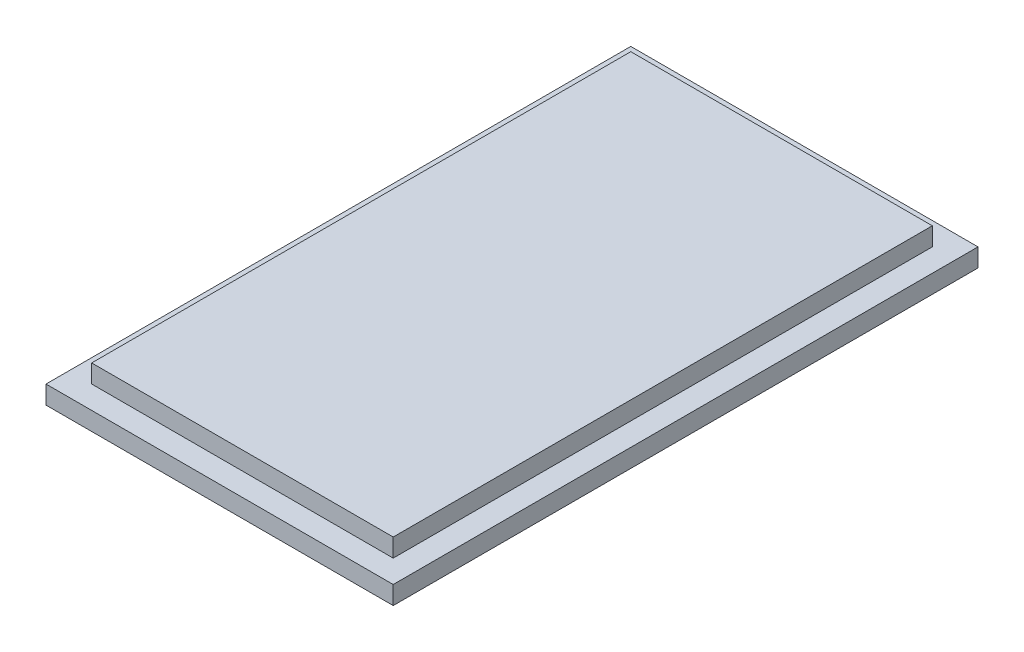
from build123d import *

# Parameters (mm, degrees)
CROQUIS1_W              = 19
CROQUIS1_H              = 32
CROQUIS1_W_2            = 16.5
CROQUIS1_H_2            = 29.5
SALIENTE_EXTRUIR1_DEPTH = 1
CROQUIS1_2_W            = 16.5
CROQUIS1_2_H            = 29.5
SALIENTE_EXTRUIR2_DEPTH = 2


with BuildPart() as part:
    # Croquis1 → Saliente-Extruir1 (new body)
    with BuildSketch(Plane(origin=(0, 0, 0), x_dir=(1, 0, 0), z_dir=(0, 1, 0))):
        with Locations((9.5, 16)):
            Rectangle(CROQUIS1_W, CROQUIS1_H)
        with Locations((9.5, 16)):
            Rectangle(CROQUIS1_W_2, CROQUIS1_H_2, mode=Mode.SUBTRACT)
    extrude(amount=SALIENTE_EXTRUIR1_DEPTH)

    # Croquis1_2 → Saliente-Extruir2 (add)
    with BuildSketch(Plane(origin=(0, 0, 0), x_dir=(1, 0, 0), z_dir=(0, 1, 0))):
        with Locations((9.5, 16)):
            Rectangle(CROQUIS1_2_W, CROQUIS1_2_H)
    extrude(amount=SALIENTE_EXTRUIR2_DEPTH)


solid = part.part
